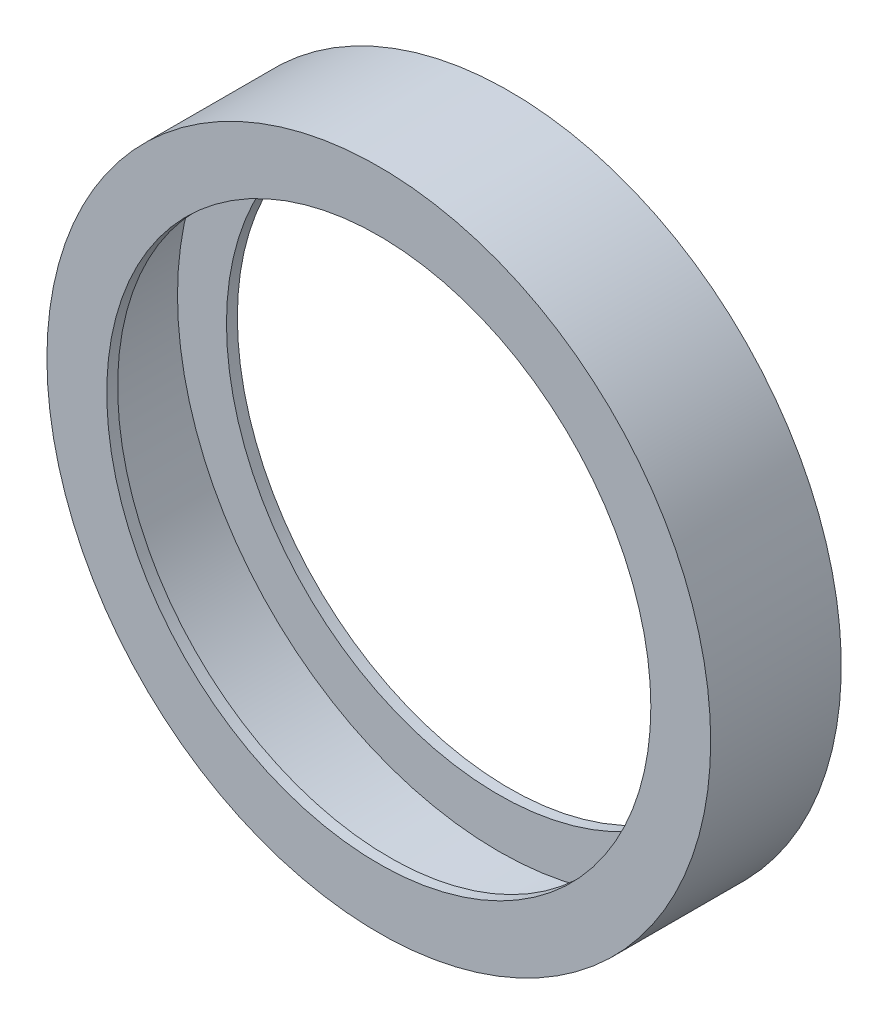
from build123d import *

# Parameters (mm, degrees)
SKETCH1_R           = 30.5
SKETCH1_R_2         = 25
BOSS_EXTRUDE1_DEPTH = 1
SKETCH2_R           = 30.5
SKETCH2_R_2         = 29.5
BOSS_EXTRUDE2_DEPTH = 10
SKETCH3_R           = 30.5
SKETCH3_R_2         = 25
BOSS_EXTRUDE3_DEPTH = 1


with BuildPart() as part:
    # Sketch1 → Boss-Extrude1 (new body)
    with BuildSketch(Plane.XY):
        Circle(SKETCH1_R)
        Circle(SKETCH1_R_2, mode=Mode.SUBTRACT)
    extrude(amount=BOSS_EXTRUDE1_DEPTH)

    # Sketch2 → Boss-Extrude2 (add)
    with BuildSketch(Plane(origin=(0, 0, 0), x_dir=(-1, 0, 0), z_dir=(0, 0, -1))):
        Circle(SKETCH2_R)
        Circle(SKETCH2_R_2, mode=Mode.SUBTRACT)
    extrude(amount=BOSS_EXTRUDE2_DEPTH)

    # Sketch3 → Boss-Extrude3 (add)
    with BuildSketch(Plane(origin=(0, 0, -10), x_dir=(-1, 0, 0), z_dir=(0, 0, -1))):
        Circle(SKETCH3_R)
        Circle(SKETCH3_R_2, mode=Mode.SUBTRACT)
    extrude(amount=BOSS_EXTRUDE3_DEPTH)


solid = part.part
